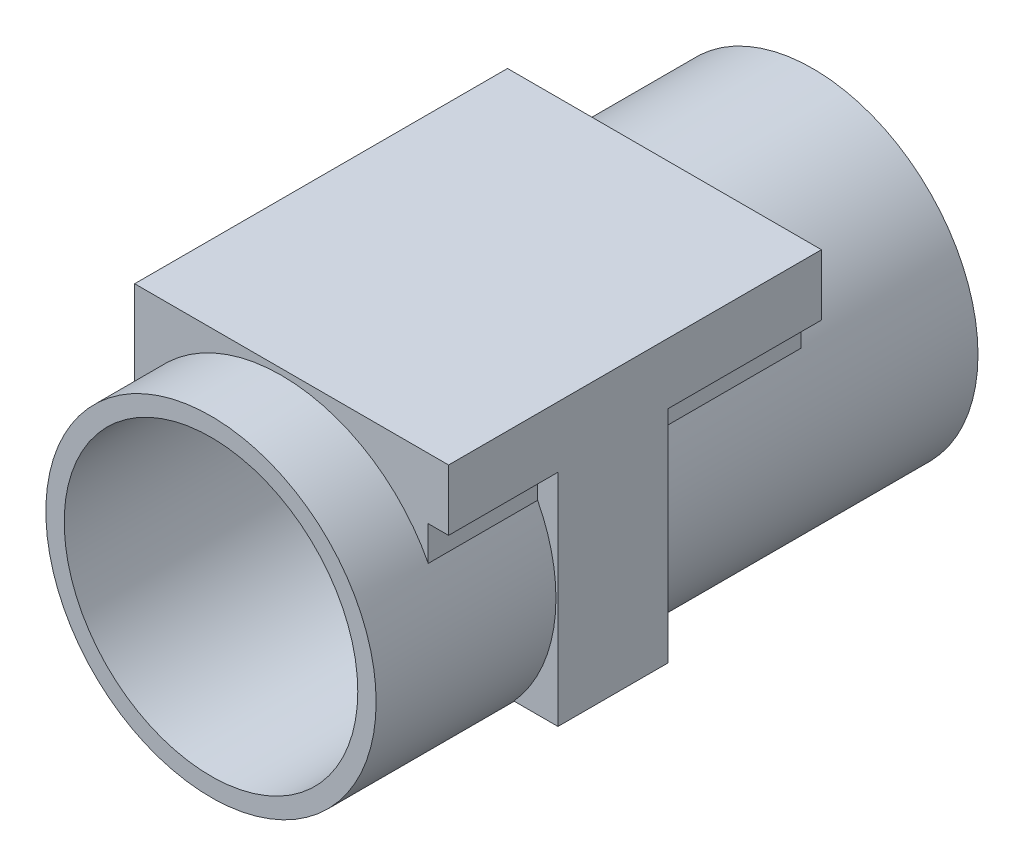
from build123d import *

# Parameters (mm, degrees)
BOSS_EXTRUDE1_DEPTH      = 7.5
BOSS_EXTRUDE1_DEPTH_BACK = 7.5
BOSS_EXTRUDE2_DEPTH      = 28.4
BOSS_EXTRUDE2_DEPTH_BACK = 22.4


with BuildPart() as part:
    # Sketch1 → Revolve1 (revolve)
    with BuildSketch(Plane(origin=(0, 0, 0), x_dir=(0, 0, -1), z_dir=(1, 0, 0))):
        Polygon((0, 0), (2, 0), (2, -22.5), (-80, -22.5), (-80, -20), (0, -20), align=None)
    revolve(axis=Axis((0, 0, 0), (0, 0, -1)))

    # Sketch3 → Boss-Extrude1 (add, two sides)
    with BuildSketch(Plane(origin=(0, 0, 48), x_dir=(-1, 0, 0), z_dir=(0, 0, -1))) as boss_extrude1_sk:
        with BuildLine():
            Line((-16.770509831, 15), (-22.770509831, 15))
            Line((-22.770509831, 15), (-22.770509831, -15))
            Line((-22.770509831, -15), (-16.770509831, -15))
            ThreePointArc((-16.770509831, -15), (-22.5, 0), (-16.770509831, 15))
        make_face()
    extrude(amount=BOSS_EXTRUDE1_DEPTH)
    extrude(boss_extrude1_sk.sketch, amount=-BOSS_EXTRUDE1_DEPTH_BACK)

    # Sketch4 → Boss-Extrude2 (add, two sides)
    with BuildSketch(Plane(origin=(0, 0, 48), x_dir=(-1, 0, 0), z_dir=(0, 0, -1))) as boss_extrude2_sk:
        with BuildLine():
            ThreePointArc((-20, 10.307764064), (0, 22.5), (20, 10.307764064))
            Line((20, 10.307764064), (20, 23.307764064))
            Line((20, 23.307764064), (-22.770509831, 23.307764064))
            Line((-22.770509831, 23.307764064), (-22.770509831, 15))
            Line((-22.770509831, 15), (-20, 15))
            Line((-20, 15), (-20, 10.307764064))
        make_face()
    extrude(amount=BOSS_EXTRUDE2_DEPTH)
    extrude(boss_extrude2_sk.sketch, amount=-BOSS_EXTRUDE2_DEPTH_BACK)


solid = part.part
